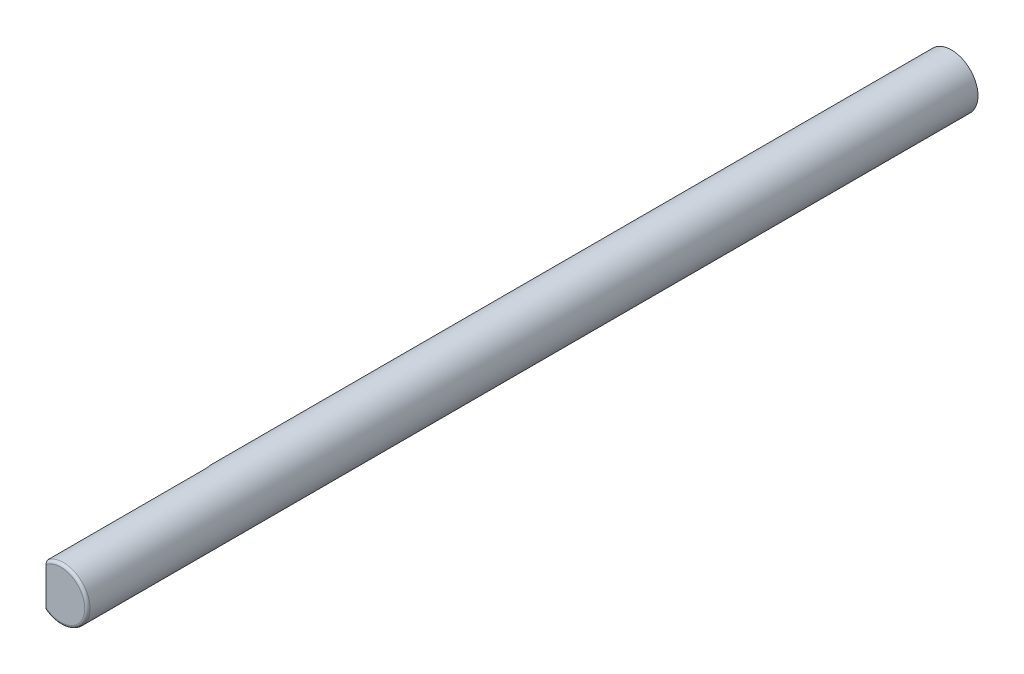
from build123d import *

# Parameters (mm, degrees)
SKETCH1_R               = 2.5
EXTRUDE1_DEPTH          = 84
FILLET1_R               = 0.25
CUT_EXTRUDE1_DEPTH      = 3
CUT_EXTRUDE1_DEPTH_BACK = 3


with BuildPart() as part:
    # Sketch1 → Extrude1 (new body)
    with BuildSketch(Plane.XY):
        Circle(SKETCH1_R)
    extrude(amount=EXTRUDE1_DEPTH)

    # Fillet1
    fillet1_edges = [part.edges().sort_by_distance(p)[0] for p in [
        (-2.5, 0, 84),
    ]]
    fillet(fillet1_edges, radius=FILLET1_R)

    # Sketch2 → Cut-Extrude1 (cut, two sides)
    with BuildSketch(Plane(origin=(0, 0, 0), x_dir=(1, 0, 0), z_dir=(0, 1, 0))) as cut_extrude1_sk:
        with BuildLine():
            Line((-1.4, -84), (-1.4, -69))
            ThreePointArc((-1.4, -69), (-1.806967498, -68.194821478), (-2.696624903, -68.045005934))
            Line((-2.696624903, -68.045005934), (-2.696624903, -84))
            Line((-2.696624903, -84), (-1.4, -84))
        make_face()
    extrude(amount=CUT_EXTRUDE1_DEPTH, mode=Mode.SUBTRACT)
    extrude(cut_extrude1_sk.sketch, amount=-CUT_EXTRUDE1_DEPTH_BACK, mode=Mode.SUBTRACT)


solid = part.part
